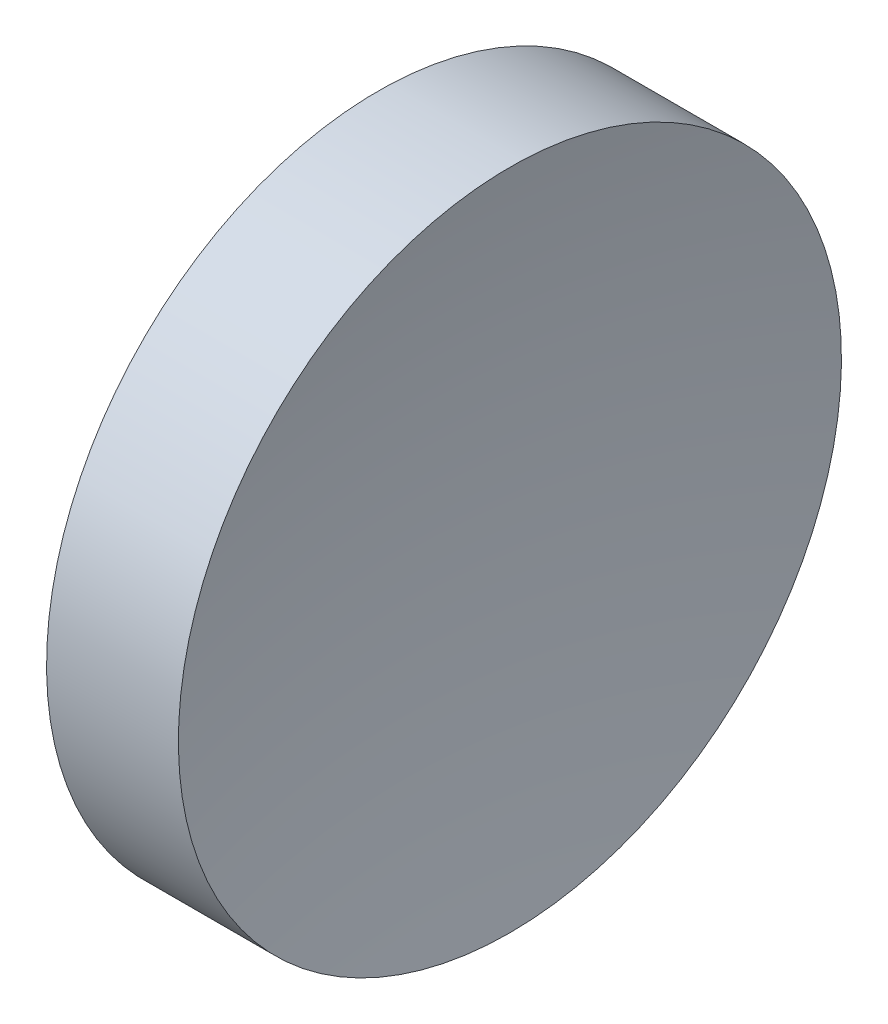
from build123d import *


with BuildPart() as part:
    # 草图1 → 旋转1 (revolve)
    with BuildSketch(Plane.XY, mode=Mode.PRIVATE) as revolve_1_sk:
        with BuildLine():
            Line((22.424232054, 13.031126091), (22.424232054, 18.031126091))
            Line((22.424232054, 18.031126091), (24.412593053, 18.031126091))
            ThreePointArc((24.412593053, 18.031126091), (24.046612104, 15.543022609), (23.924232054, 13.031126091))
            Line((23.924232054, 13.031126091), (22.424232054, 13.031126091))
        make_face()
    revolve(revolve_1_sk.sketch.rotate(Axis((21.505975118, 13.031126091, 0), (1, 0, 0)), 180), axis=Axis((21.505975118, 13.031126091, 0), (1, 0, 0)))  # turned: the seam where the file's is


solid = part.part
